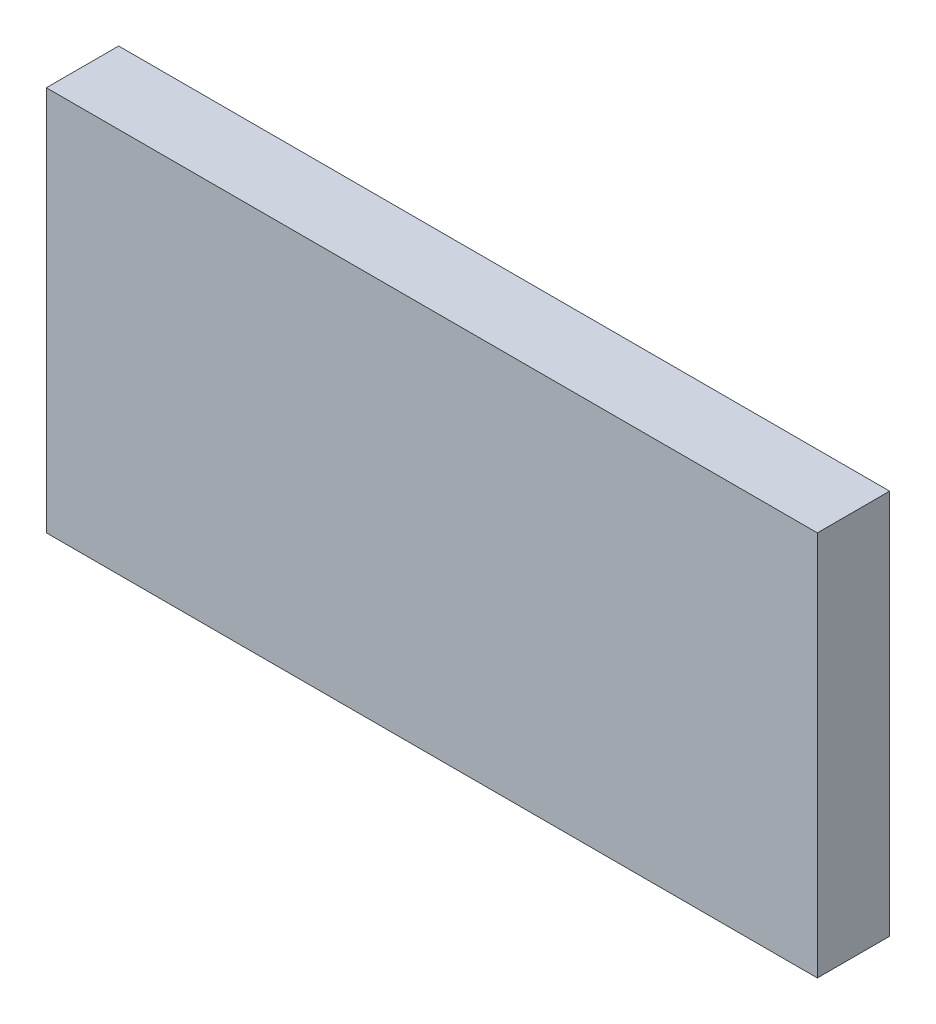
from build123d import *

# Parameters (mm, degrees)
ESQUISSE1_W      = 8
ESQUISSE1_H      = 4
EXTRUSION1_DEPTH = 0.75


with BuildPart() as part:
    # Esquisse1 → Extrusion1 (new body)
    with BuildSketch(Plane.XY):
        with Locations((4, 2)):
            Rectangle(ESQUISSE1_W, ESQUISSE1_H)
    extrude(amount=EXTRUSION1_DEPTH)


solid = part.part
